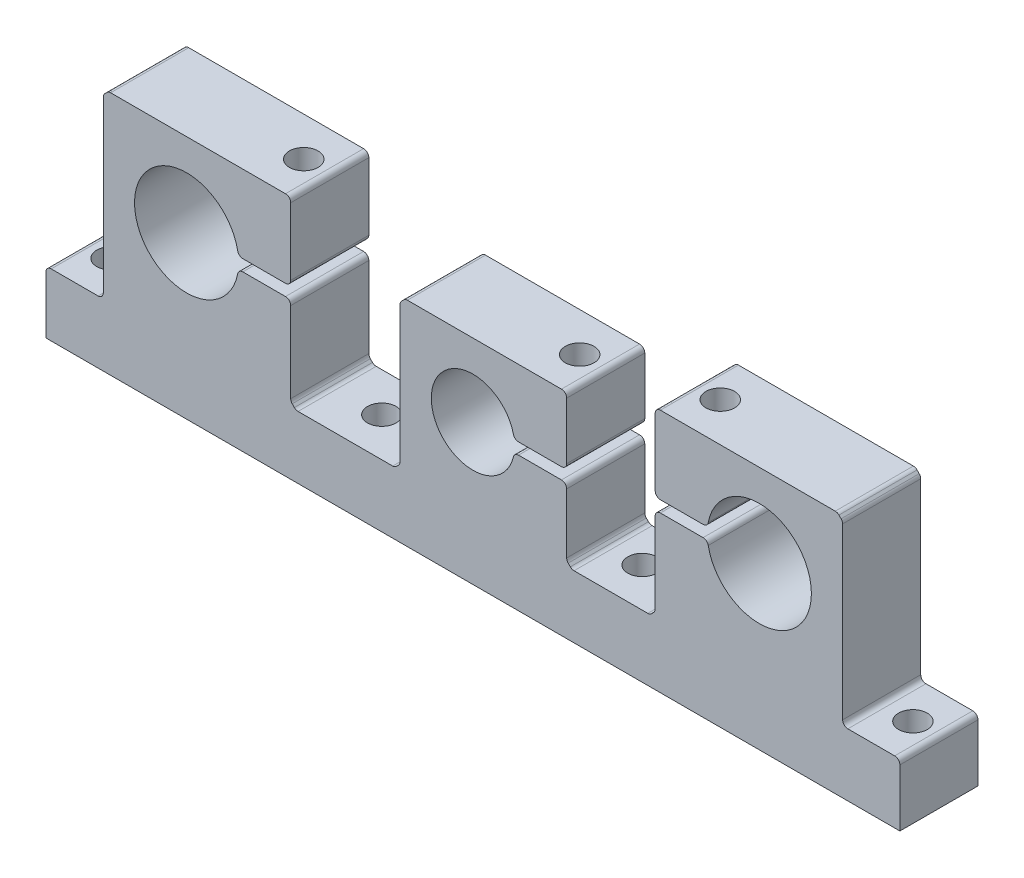
from build123d import *

# Parameters (mm, degrees)
BOSS_EXTRUDE1_DEPTH            = 15
CUT_EXTRUDE1_REACH             = 17
SKETCH2_R                      = 8
CUT_EXTRUDE2_REACH             = 17
SKETCH3_R                      = 10
F_5_5_5_5_DIAMETER_HOLE1_D     = 5.5
F_5_5_5_5_DIAMETER_HOLE1_DEPTH = 12
CUT_EXTRUDE3_REACH             = 17
CUT_EXTRUDE4_REACH             = 17
F_5_5_5_5_DIAMETER_HOLE2_D     = 5.5
F_5_5_5_5_DIAMETER_HOLE2_DEPTH = 14.9
F_5_5_5_5_DIAMETER_HOLE3_D     = 5.5
F_5_5_5_5_DIAMETER_HOLE3_DEPTH = 18.9
M5_TAPPED_HOLE2_D              = 4.2
M5_TAPPED_HOLE2_DEPTH          = 14
M5_TAPPED_HOLE2_TIP            = 1.2618073
CHAMFER1_SIZE                  = 1
CHAMFER2_SIZE                  = 1
CHAMFER3_SIZE                  = 1
FILLET1_R                      = 1
F_5_5_5_5_DIAMETER_HOLE4_D     = 5.5


with BuildPart() as part:
    # Sketch1 → Boss-Extrude1 (new body)
    with BuildSketch(Plane.XY):
        Polygon((82, 0), (-82, 0), (-82, 12), (-71, 12), (-71, 47), (71, 47), (71, 12), (82, 12), align=None)
    extrude(amount=BOSS_EXTRUDE1_DEPTH)

    # Sketch2 → Cut-Extrude1 (cut, up to next)
    with BuildSketch(Plane.XY.offset(15), mode=Mode.PRIVATE) as cut_extrude1_sk1:
        with Locations((0, 27)):
            Circle(SKETCH2_R)
    cut_extrude1_tool1 = extrude(cut_extrude1_sk1.sketch, amount=-CUT_EXTRUDE1_REACH, mode=Mode.PRIVATE) & part.part
    add(cut_extrude1_tool1.solids().sort_by_distance((0, 27, 15))[0], mode=Mode.SUBTRACT)

    # Sketch3 → Cut-Extrude2 (cut, up to next)
    with BuildSketch(Plane(origin=(0, 0, 0), x_dir=(-1, 0, 0), z_dir=(0, 0, -1)), mode=Mode.PRIVATE) as cut_extrude2_sk1:
        with Locations((-55, 31)):
            Circle(SKETCH3_R)
    cut_extrude2_tool1 = extrude(cut_extrude2_sk1.sketch, amount=-CUT_EXTRUDE2_REACH, mode=Mode.PRIVATE) & part.part
    add(cut_extrude2_tool1.solids().sort_by_distance((55, 31, 0))[0], mode=Mode.SUBTRACT)
    # Sketch3 → Cut-Extrude2 (cut, up to next)
    with BuildSketch(Plane(origin=(0, 0, 0), x_dir=(-1, 0, 0), z_dir=(0, 0, -1)), mode=Mode.PRIVATE) as cut_extrude2_sk2:
        with Locations((55, 31)):
            Circle(SKETCH3_R)
    cut_extrude2_tool2 = extrude(cut_extrude2_sk2.sketch, amount=-CUT_EXTRUDE2_REACH, mode=Mode.PRIVATE) & part.part
    add(cut_extrude2_tool2.solids().sort_by_distance((-55, 31, 0))[0], mode=Mode.SUBTRACT)

    # Ø5.5 (5.5) Diameter Hole1
    with Locations(Plane(origin=(-77, 12, 7.5), x_dir=(0, 0, 1), z_dir=(0, 1, 0))):
        with Locations((0, 0), (0, 154)):
            Hole(F_5_5_5_5_DIAMETER_HOLE1_D / 2, depth=F_5_5_5_5_DIAMETER_HOLE1_DEPTH)

    # Sketch9 → Cut-Extrude3 (cut, up to next)
    with BuildSketch(Plane.XY.offset(15), mode=Mode.PRIVATE) as cut_extrude3_sk1:
        Polygon((0, 41), (-14, 41), (-14, 12), (-35, 12), (-35, 47), (35, 47), (35, 12), (18, 12), (18, 41), align=None)
    cut_extrude3_tool1 = extrude(cut_extrude3_sk1.sketch, amount=-CUT_EXTRUDE3_REACH, mode=Mode.PRIVATE) & part.part
    add(cut_extrude3_tool1.solids().sort_by_distance((-7, 41.782624, 15))[0], mode=Mode.SUBTRACT)

    # Sketch10 → Cut-Extrude4 (cut, up to next)
    with BuildSketch(Plane.XY.offset(15), mode=Mode.PRIVATE) as cut_extrude4_sk1:
        Polygon((-55, 31), (-55, 32.1), (-35, 32.1), (-35, 29.9), (-55, 29.9), align=None)
    cut_extrude4_tool1 = extrude(cut_extrude4_sk1.sketch, amount=-CUT_EXTRUDE4_REACH, mode=Mode.PRIVATE) & part.part
    add(cut_extrude4_tool1.solids().sort_by_distance((-45, 31, 15))[0], mode=Mode.SUBTRACT)
    # Sketch10 → Cut-Extrude4 (cut, up to next)
    with BuildSketch(Plane.XY.offset(15), mode=Mode.PRIVATE) as cut_extrude4_sk2:
        Polygon((55, 31), (55, 32.1), (35, 32.1), (35, 29.9), (55, 29.9), align=None)
    cut_extrude4_tool2 = extrude(cut_extrude4_sk2.sketch, amount=-CUT_EXTRUDE4_REACH, mode=Mode.PRIVATE) & part.part
    add(cut_extrude4_tool2.solids().sort_by_distance((45, 31, 15))[0], mode=Mode.SUBTRACT)
    # Sketch10 → Cut-Extrude4 (cut, up to next)
    with BuildSketch(Plane.XY.offset(15), mode=Mode.PRIVATE) as cut_extrude4_sk3:
        Polygon((0, 27), (0, 28.1), (18, 28.1), (18, 25.9), (0, 25.9), align=None)
    cut_extrude4_tool3 = extrude(cut_extrude4_sk3.sketch, amount=-CUT_EXTRUDE4_REACH, mode=Mode.PRIVATE) & part.part
    add(cut_extrude4_tool3.solids().sort_by_distance((9, 27, 15))[0], mode=Mode.SUBTRACT)

    # Ø5.5 (5.5) Diameter Hole2
    with Locations(Plane(origin=(-40, 47, 7.5), x_dir=(0, 0, 1), z_dir=(0, 1, 0))):
        with Locations((0, 0), (0, 80)):
            Hole(F_5_5_5_5_DIAMETER_HOLE2_D / 2, depth=F_5_5_5_5_DIAMETER_HOLE2_DEPTH)

    # Ø5.5 (5.5) Diameter Hole3
    with Locations(Plane(origin=(13, 47, 7.5), x_dir=(0, 0, 1), z_dir=(0, 1, 0))):
        with Locations((0, 0)):
            Hole(F_5_5_5_5_DIAMETER_HOLE3_D / 2, depth=F_5_5_5_5_DIAMETER_HOLE3_DEPTH)

    # M5 Tapped Hole2
    with Locations(Plane(origin=(-40, 29.9, 7.5), x_dir=(0, 0, 1), z_dir=(0, 1, 0))):
        with Locations((0, 0), (0, 80)):
            Hole(M5_TAPPED_HOLE2_D / 2, depth=M5_TAPPED_HOLE2_DEPTH)
            with Locations((0, 0, -(M5_TAPPED_HOLE2_DEPTH + M5_TAPPED_HOLE2_TIP / 2))):  # 118° drill point
                Cone(0, M5_TAPPED_HOLE2_D / 2, M5_TAPPED_HOLE2_TIP, mode=Mode.SUBTRACT)

    # Chamfer1
    chamfer1_edges = [part.edges().sort_by_distance(p)[0] for p in [
        (-71, 47, 7.5),
        (71, 47, 7.5),
    ]]
    chamfer(chamfer1_edges, length=CHAMFER1_SIZE)

    # Chamfer2
    chamfer2_edges = [part.edges().sort_by_distance(p)[0] for p in [
        (-14, 41, 7.5),
    ]]
    chamfer(chamfer2_edges, length=CHAMFER2_SIZE)

    # Chamfer3
    chamfer3_edges = [part.edges().sort_by_distance(p)[0] for p in [
        (-14, 12, 7.5),
        (-35, 12, 7.5),
        (35, 12, 7.5),
        (18, 12, 7.5),
    ]]
    chamfer(chamfer3_edges, length=CHAMFER3_SIZE)

    # Fillet1
    fillet1_edges = [part.edges().sort_by_distance(p)[0] for p in [
        (35, 29.9, 7.5),
        (35, 32.1, 7.5),
        (45.060684128, 29.9, 7.5),
        (45.060684128, 32.1, 7.5),
        (18, 28.1, 7.5),
        (18, 25.9, 7.5),
        (7.924014134, 28.1, 7.5),
        (7.924014134, 25.9, 7.5),
        (71, 12, 7.5),
        (82, 12, 7.5),
        (-82, 12, 7.5),
        (-71, 12, 7.5),
        (-71, 46, 7.5),
        (-70, 47, 7.5),
        (70, 47, 7.5),
        (71, 46, 7.5),
        (-13, 41, 7.5),
        (-14, 40, 7.5),
        (35, 13, 7.5),
        (19, 12, 7.5),
        (34, 12, 7.5),
        (18, 13, 7.5),
        (-14, 13, 7.5),
        (-34, 12, 7.5),
        (-15, 12, 7.5),
        (-35, 13, 7.5),
        (18, 41, 7.5),
        (-35, 47, 7.5),
        (35, 47, 7.5),
        (-45.060684128, 32.1, 7.5),
        (-45.060684128, 29.9, 7.5),
        (-35, 32.1, 7.5),
        (-35, 29.9, 7.5),
    ]]
    fillet(fillet1_edges, radius=FILLET1_R)

    # Ø5.5 (5.5) Diameter Hole4 (through all)
    with Locations(Plane(origin=(-25, 12, 7.5), x_dir=(1, 0, 0), z_dir=(0, 1, 0))):
        with Locations((0, 0), (50, 0)):
            Hole(F_5_5_5_5_DIAMETER_HOLE4_D / 2)


solid = part.part
